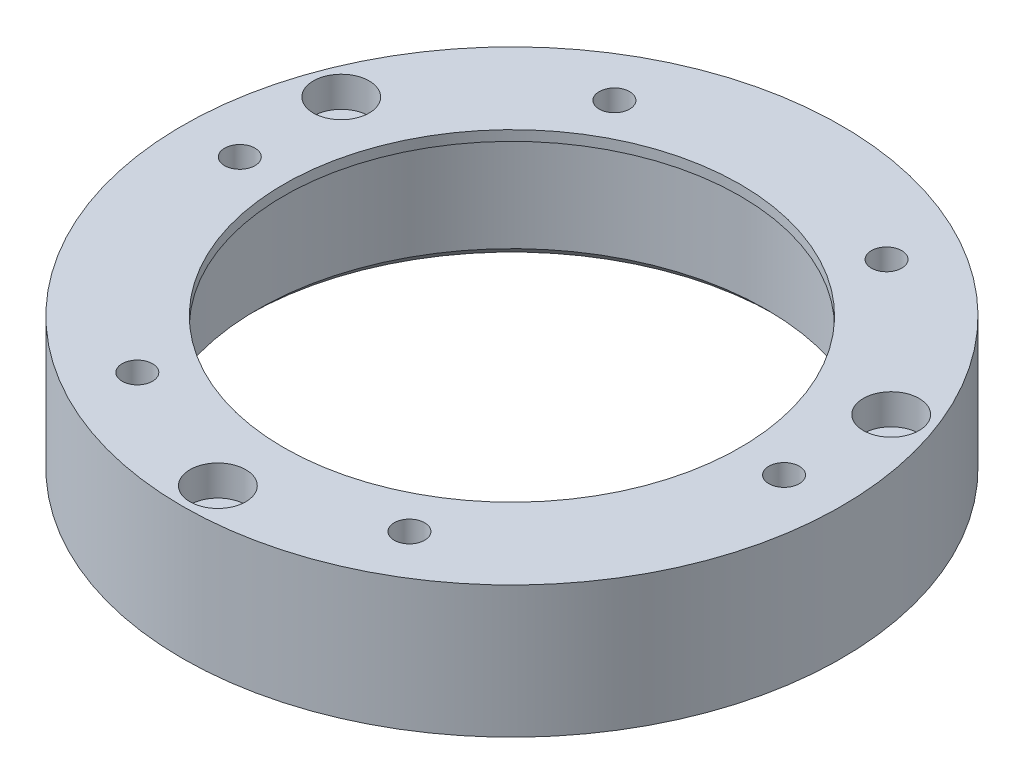
from build123d import *

# Parameters (mm, degrees)
SKETCH1_R           = 32.5
SKETCH1_R_2         = 25.1
BOSS_EXTRUDE1_DEPTH = 13
SKETCH2_R           = 25.1
SKETCH2_R_2         = 22.5
BOSS_EXTRUDE2_DEPTH = 1
SKETCH3_R           = 1.5
CUT_EXTRUDE1_DEPTH  = 14
CHAMFER1_SIZE       = 1
SKETCH4_R           = 2.75
CUT_EXTRUDE2_DEPTH  = 3
SKETCH5_R           = 1.5
CUT_EXTRUDE3_DEPTH  = 10


with BuildPart() as part:
    # Sketch1 → Boss-Extrude1 (new body)
    with BuildSketch(Plane(origin=(0, 0, 0), x_dir=(1, 0, 0), z_dir=(0, 1, 0))):
        Circle(SKETCH1_R)
        Circle(SKETCH1_R_2, mode=Mode.SUBTRACT)
    extrude(amount=BOSS_EXTRUDE1_DEPTH)

    # Sketch2 → Boss-Extrude2 (add)
    with BuildSketch(Plane(origin=(0, 13, 0), x_dir=(1, 0, 0), z_dir=(0, 1, 0))):
        Circle(SKETCH2_R)
        Circle(SKETCH2_R_2, mode=Mode.SUBTRACT)
    extrude(amount=-BOSS_EXTRUDE2_DEPTH)

    # Sketch3 → Cut-Extrude1 (cut, through all)
    with BuildSketch(Plane(origin=(0, 0, 0), x_dir=(-1, 0, 0), z_dir=(0, -1, 0))):
        with Locations((0, -29)):
            Circle(SKETCH3_R)
        with Locations((-27.115332973, 10.283905765)):
            Circle(SKETCH3_R)
        with Locations((27.115332973, 10.283905765)):
            Circle(SKETCH3_R)
    extrude(amount=-CUT_EXTRUDE1_DEPTH, mode=Mode.SUBTRACT)

    # Chamfer1
    chamfer1_edges = [part.edges().sort_by_distance(p)[0] for p in [
        (-25.1, 0, 0),
    ]]
    chamfer(chamfer1_edges, length=CHAMFER1_SIZE)

    # Sketch4 → Cut-Extrude2 (cut)
    with BuildSketch(Plane(origin=(0, 13, 0), x_dir=(1, 0, 0), z_dir=(0, 1, 0))):
        with Locations((-27.115332973, 10.283905765)):
            Circle(SKETCH4_R)
        with Locations((27.115332973, 10.283905765)):
            Circle(SKETCH4_R)
        with Locations((0, -29)):
            Circle(SKETCH4_R)
    extrude(amount=-CUT_EXTRUDE2_DEPTH, mode=Mode.SUBTRACT)

    # Sketch5 → Cut-Extrude3 (cut)
    with BuildSketch(Plane(origin=(0, 13, 0), x_dir=(1, 0, 0), z_dir=(0, 1, 0))):
        with Locations((13.641823983, 23.300228291)):
            Circle(SKETCH5_R)
        with Locations((26.999501606, -0.164051977)):
            Circle(SKETCH5_R)
        with Locations((13.357677623, -23.464280269)):
            Circle(SKETCH5_R)
        with Locations((-13.641823983, -23.300228291)):
            Circle(SKETCH5_R)
        with Locations((-26.999501606, 0.164051977)):
            Circle(SKETCH5_R)
        with Locations((-13.357677623, 23.464280269)):
            Circle(SKETCH5_R)
    extrude(amount=-CUT_EXTRUDE3_DEPTH, mode=Mode.SUBTRACT)


solid = part.part
